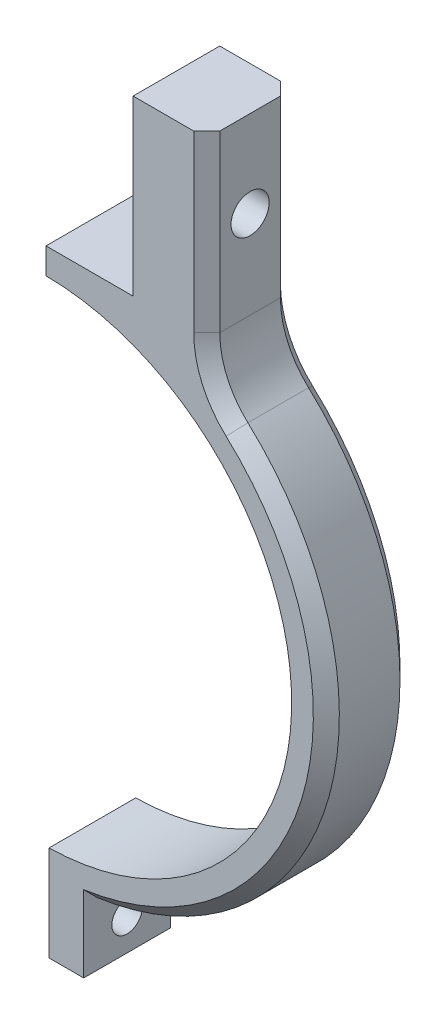
from build123d import *

# Parameters (mm, degrees)
AUFSATZ_LINEAR_AUSTRAGEN1_DEPTH = 10
SKIZZE2_R                       = 1.75
SCHNITT_LINEAR_AUSTRAGEN1_DEPTH = 38
SKIZZE4_R                       = 2.2
SCHNITT_LINEAR_AUSTRAGEN3_DEPTH = 52.2
VERRUNDUNG1_R                   = 10
SKIZZE5_W                       = 5.5
SKIZZE5_H                       = 5.5
SCHNITT_LINEAR_AUSTRAGEN4_DEPTH = 2
FASE1_SIZE                      = 1.5
SCHNITT_LINEAR_AUSTRAGEN5_DEPTH = 11


with BuildPart() as part:
    # Skizze1 → Aufsatz-Linear austragen1 (new body)
    with BuildSketch(Plane.XY):
        with BuildLine():
            Line((0.5, -28.495613698), (0.5, -32.496153619))
            Line((0.5, -32.496153619), (0.5, -39.496153619))
            Line((0.5, -39.496153619), (4.5, -39.496153619))
            Line((4.5, -39.496153619), (4.5, -32.186953879))
            ThreePointArc((4.5, -32.186953879), (31.590882714, -7.633225356), (18.7, 26.581196361))
            Line((18.7, 26.581196361), (18.7, 51.5))
            Line((18.7, 51.5), (10.2, 51.5))
            Line((10.2, 51.5), (10.2, 31.5))
            Line((10.2, 31.5), (-10.2, 31.5))
            Line((-10.2, 31.5), (-10.2, 51.5))
            Line((-10.2, 51.5), (-18.7, 51.5))
            Line((-18.7, 51.5), (-18.7, 26.581196361))
            ThreePointArc((-18.7, 26.581196361), (-31.590882714, -7.633225356), (-4.5, -32.186953879))
            Line((-4.5, -32.186953879), (-4.5, -39.496153619))
            Line((-4.5, -39.496153619), (-0.5, -39.496153619))
            Line((-0.5, -39.496153619), (-0.5, -32.496153619))
            Line((-0.5, -32.496153619), (-0.5, -28.495613698))
            ThreePointArc((-0.5, -28.495613698), (0, 28.5), (0.5, -28.495613698))
        make_face()
    extrude(amount=AUFSATZ_LINEAR_AUSTRAGEN1_DEPTH)

    # Skizze2 → Schnitt-Linear austragen1 (cut, through all)
    with BuildSketch(Plane.ZY.offset(4.5)):
        with Locations((5, -35.841553749)):
            Circle(SKIZZE2_R)
    extrude(amount=-SCHNITT_LINEAR_AUSTRAGEN1_DEPTH, mode=Mode.SUBTRACT)

    # Skizze4 → Schnitt-Linear austragen3 (cut, through all)
    with BuildSketch(Plane.ZY.offset(18.7)):
        with Locations((5, 41.5)):
            Circle(SKIZZE4_R)
    extrude(amount=-SCHNITT_LINEAR_AUSTRAGEN3_DEPTH, mode=Mode.SUBTRACT)

    # Verrundung1
    verrundung1_edges = [part.edges().sort_by_distance(p)[0] for p in [
        (-18.7, 26.581196361, 5),
        (18.7, 26.581196361, 5),
    ]]
    fillet(verrundung1_edges, radius=VERRUNDUNG1_R)

    # Skizze5 → Schnitt-Linear austragen4 (cut)
    with BuildSketch(Plane.ZY.offset(4.5)):
        with Locations((5, -35.841553749)):
            Rectangle(SKIZZE5_W, SKIZZE5_H)
    extrude(amount=-SCHNITT_LINEAR_AUSTRAGEN4_DEPTH, mode=Mode.SUBTRACT)

    # Fase1
    fase1_edges = [part.edges().sort_by_distance(p)[0] for p in [
        (-18.7, 41.422906559, 0),
        (31.036620275, -9.642520517, 0),
        (-18.7, 41.422906559, 10),
        (18.7, 41.422906559, 0),
        (18.7, 41.422906559, 10),
        (31.036620275, -9.642520517, 10),
        (-31.036620275, -9.642520517, 0),
        (-31.036620275, -9.642520517, 10),
        (19.547693958, 27.316508696, 0),
        (19.547693958, 27.316508696, 10),
        (-19.547693958, 27.316508696, 0),
        (-19.547693958, 27.316508696, 10),
    ]]
    chamfer(fase1_edges, length=FASE1_SIZE)

    # Skizze6 → Schnitt-Linear austragen5 (cut, through all)
    with BuildSketch(Plane.XY):
        Polygon((0, -82.914559746), (0, 27.830541285), (0.15, 27.830541285), (0.15, 32.208374164), (0, 32.208374164), (0, 82.914559746), (-62.169798489, 71.020337849), (-62.169798489, -54.918482242), align=None)
    extrude(amount=SCHNITT_LINEAR_AUSTRAGEN5_DEPTH, mode=Mode.SUBTRACT)


solid = part.part
